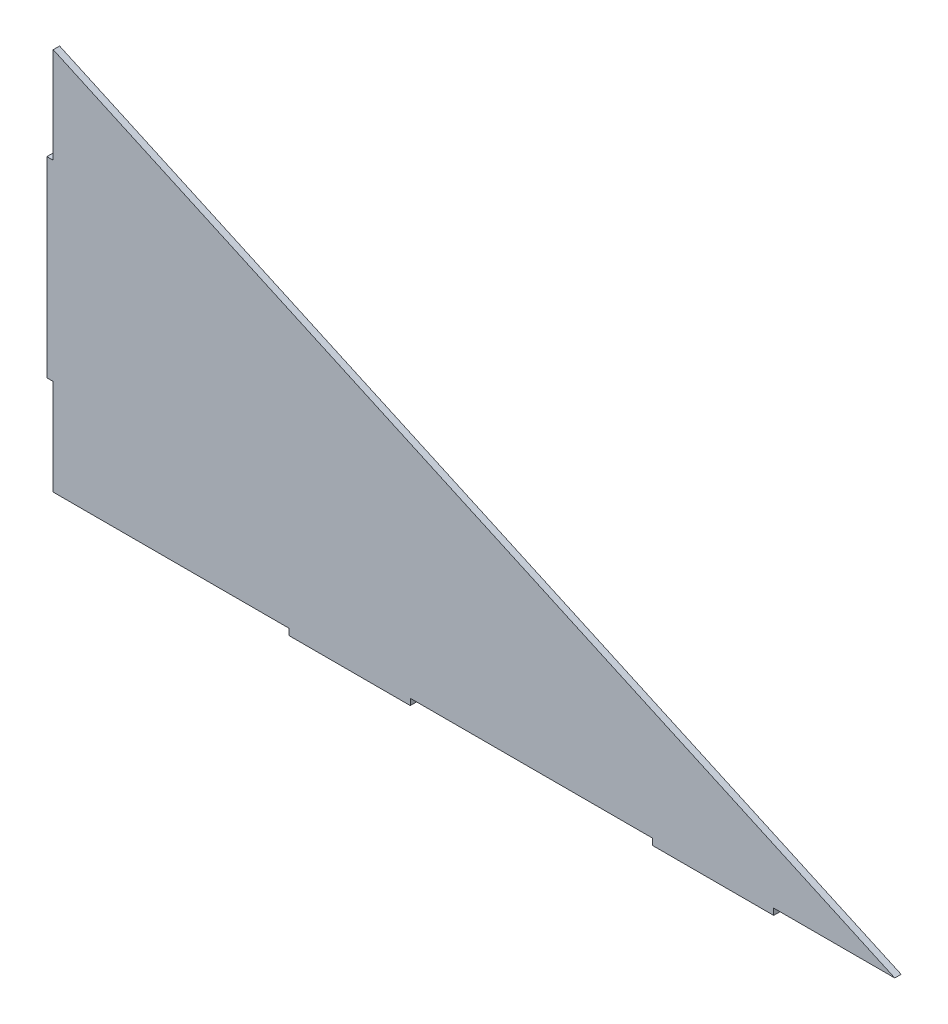
from build123d import *

# Parameters (mm, degrees)
RESSALTO_EXTRUS_O1_DEPTH = 3


with BuildPart() as part:
    # Esboço1 → Ressalto-extrusão1 (new body)
    with BuildSketch(Plane.XY):
        Polygon((0, 0), (0, 45.190611635), (-3, 45.190611635), (-3, 135.571834905), (0, 135.571834905), (0, 180.76244654), (397, 0), (339.85714285, 0), (339.85714285, -3), (282.7142857, -3), (282.7142857, 0), (168.4285714, 0), (168.4285714, -3), (111.28571425, -3), (111.28571425, 0), align=None)
    extrude(amount=RESSALTO_EXTRUS_O1_DEPTH)


solid = part.part
